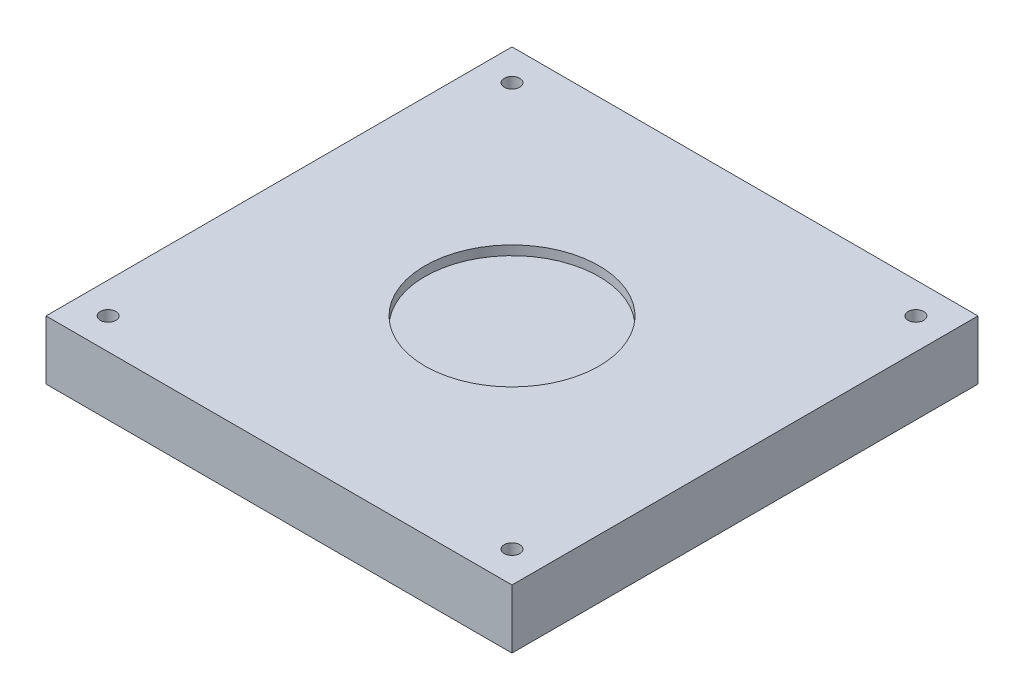
from build123d import *

# Parameters (mm, degrees)
SKETCH1_W           = 150
SKETCH1_H           = 150
BOSS_EXTRUDE1_DEPTH = 19
SKETCH2_R           = 28
CUT_EXTRUDE1_DEPTH  = 3
SKETCH4_R           = 2.5
CUT_EXTRUDE2_DEPTH  = 6.35


with BuildPart() as part:
    # Sketch1 → Boss-Extrude1 (new body)
    with BuildSketch(Plane(origin=(0, 0, 0), x_dir=(1, 0, 0), z_dir=(0, 1, 0))):
        with Locations((75, 75)):
            Rectangle(SKETCH1_W, SKETCH1_H)
    extrude(amount=BOSS_EXTRUDE1_DEPTH)

    # Sketch2 → Cut-Extrude1 (cut)
    with BuildSketch(Plane(origin=(0, 19, 0), x_dir=(1, 0, 0), z_dir=(0, 1, 0))):
        with Locations((75, 75)):
            Circle(SKETCH2_R)
    extrude(amount=-CUT_EXTRUDE1_DEPTH, mode=Mode.SUBTRACT)

    # Sketch4 → Cut-Extrude2 (cut)
    with BuildSketch(Plane(origin=(0, 19, 0), x_dir=(1, 0, 0), z_dir=(0, 1, 0))):
        with Locations((10, 140)):
            Circle(SKETCH4_R)
        with Locations((140, 140)):
            Circle(SKETCH4_R)
        with Locations((140, 10)):
            Circle(SKETCH4_R)
        with Locations((10, 10)):
            Circle(SKETCH4_R)
    extrude(amount=-CUT_EXTRUDE2_DEPTH, mode=Mode.SUBTRACT)


solid = part.part
